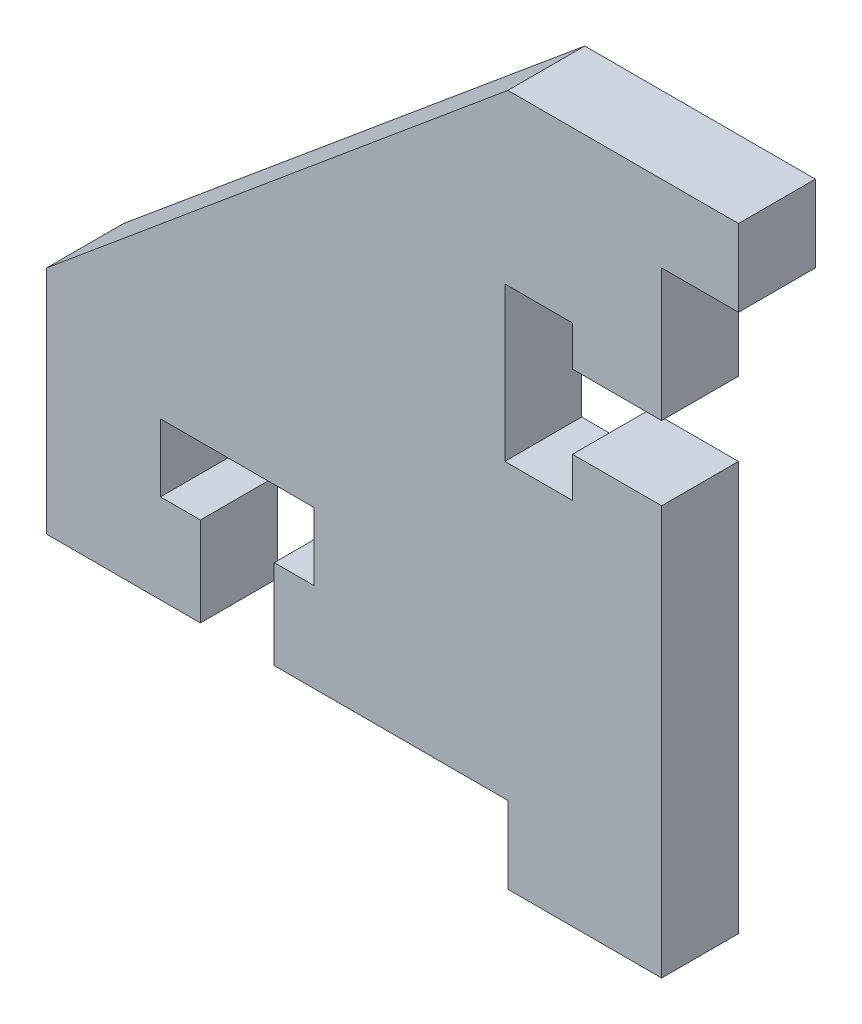
from build123d import *

# Parameters (mm, degrees)
BOSS_EXTRUDE1_DEPTH = 3.175


with BuildPart() as part:
    # Sketch1 → Boss-Extrude1 (new body)
    with BuildSketch(Plane.XY):
        Polygon((-6.35, 11.684), (3.175, 11.684), (3.175, 8.509), (0, 8.509), (0, 3.048), (-3.683, 3.048), (-3.683, 4.699), (-6.477, 4.699), (-6.477, -1.651), (-3.683, -1.651), (-3.683, 0), (0, 0), (0, -16.891), (-6.35, -16.891), (-6.35, -13.716), (-16.002, -13.716), (-16.002, -10.033), (-14.351, -10.033), (-14.351, -7.239), (-20.701, -7.239), (-20.701, -10.033), (-19.05, -10.033), (-19.05, -13.716), (-25.4, -13.716), (-25.4, -4.191), align=None)
    extrude(amount=BOSS_EXTRUDE1_DEPTH)


solid = part.part
